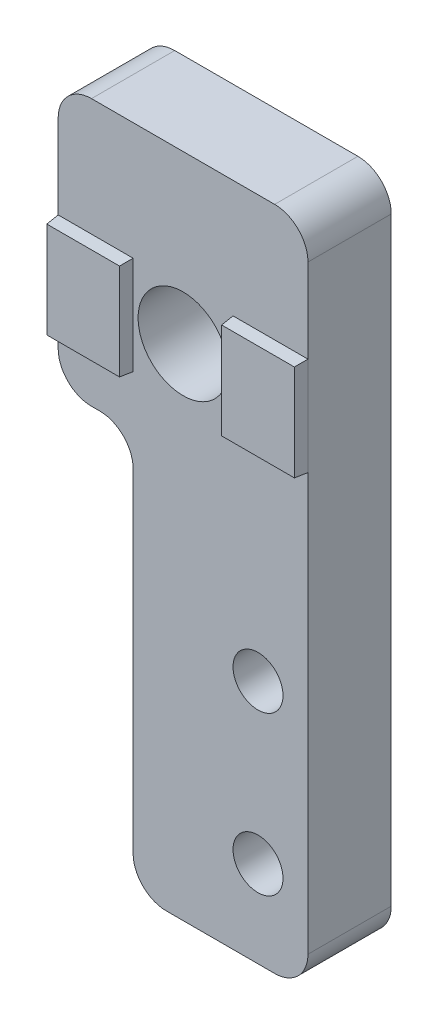
from build123d import *

# Parameters (mm, degrees)
SKETCH1_R           = 2.7
SKETCH1_R_2         = 1.5
BOSS_EXTRUDE1_DEPTH = 5
SKETCH2_W           = 4.5
SKETCH2_H           = 5.9
BOSS_EXTRUDE2_DEPTH = 0.75
BOSS_EXTRUDE2_TAPER = 5


with BuildPart() as part:
    # Sketch1 → Boss-Extrude1 (new body)
    with BuildSketch(Plane.XY):
        with BuildLine():
            Line((0, -2), (0, -14))
            ThreePointArc((0, -14), (0.585786438, -15.414213562), (2, -16))
            Line((2, -16), (2.5, -16))
            ThreePointArc((2.5, -16), (3.914213562, -16.585786438), (4.5, -18))
            Line((4.5, -18), (4.5, -38))
            ThreePointArc((4.5, -38), (5.085786438, -39.414213562), (6.5, -40))
            Line((6.5, -40), (13, -40))
            ThreePointArc((13, -40), (14.414213562, -39.414213562), (15, -38))
            Line((15, -38), (15, -2))
            ThreePointArc((15, -2), (14.414213562, -0.585786438), (13, 0))
            Line((13, 0), (2, 0))
            ThreePointArc((2, 0), (0.585786438, -0.585786438), (0, -2))
        make_face()
        with Locations((7.5, -10)):
            Circle(SKETCH1_R, mode=Mode.SUBTRACT)
        with Locations((12, -34.8)):
            Circle(SKETCH1_R_2, mode=Mode.SUBTRACT)
        with Locations((12, -25.3)):
            Circle(SKETCH1_R_2, mode=Mode.SUBTRACT)
    extrude(amount=BOSS_EXTRUDE1_DEPTH)

    # Sketch2 → Boss-Extrude2 (add)
    with BuildSketch(Plane.XY.offset(5)):
        with Locations((2.25, -10)):
            Rectangle(SKETCH2_W, SKETCH2_H)
        with Locations((12.75, -10)):
            Rectangle(SKETCH2_W, SKETCH2_H)
    extrude(amount=BOSS_EXTRUDE2_DEPTH, taper=BOSS_EXTRUDE2_TAPER)


solid = part.part
